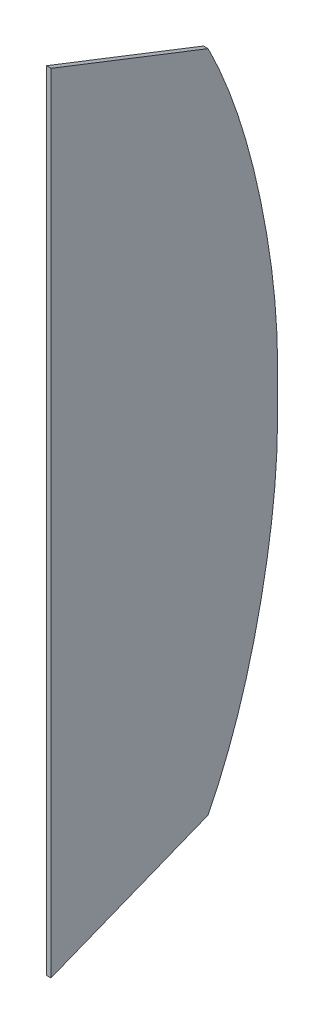
from build123d import *

# Parameters (mm, degrees)
EXTRUDE_3_DEPTH = 6


with BuildPart() as part:
    # Эскиз1 → Бобышка-Вытянуть3 (new body)
    with BuildSketch(Plane(origin=(0, 0, 0), x_dir=(0, 0, -1), z_dir=(1, 0, 0))):
        with BuildLine():
            Line((-455, -516.542644104), (-455, 516.556548518))
            Line((-455, 516.556548518), (-248.999999692, 435.905604479))
            add(Edge.make_bspline(
                [(-248.999999692, 435.905604479), (-244.812182794, 427.580683135), (-236.801363167, 410.73826292), (-222.212406758, 376.463926678), (-206.472110198, 332.573595341), (-191.065214882, 278.622516157), (-178.618404528, 223.741954043), (-168.601235151, 168.376182512), (-162.664180548, 121.995794186), (-159.588454358, 84.78039118), (-158.191016915, 56.847307797), (-157.699086883, 28.820440013), (-157.668208508, 0.657149051), (-157.69908686, -27.506141911), (-158.191016904, -55.533009684), (-159.588454431, -83.466093036), (-162.664180797, -120.681496001), (-168.601235656, -167.061884287), (-178.618405136, -222.427655869), (-191.065215126, -277.308218149), (-206.47210996, -331.259297463), (-222.212406313, -375.149628797), (-236.801362845, -409.423964908), (-244.812182664, -426.266385019), (-248.999999692, -434.591306286)],
                knots=[0.002534483, 0.002534483, 0.002534483, 0.002534483, 0.033626078, 0.064717673, 0.126900862, 0.189084052, 0.251267242, 0.313450431, 0.375633621, 0.406725216, 0.43781681, 0.468908405, 0.5, 0.531091595, 0.56218319, 0.593274784, 0.624366379, 0.686549569, 0.748732758, 0.810915948, 0.873099138, 0.935282327, 0.966373922, 0.997465517, 0.997465517, 0.997465517, 0.997465517], degree=3))
            Line((-248.999999692, -434.591306286), (-455, -516.542644104))
        make_face()
    extrude(amount=EXTRUDE_3_DEPTH)


solid = part.part
